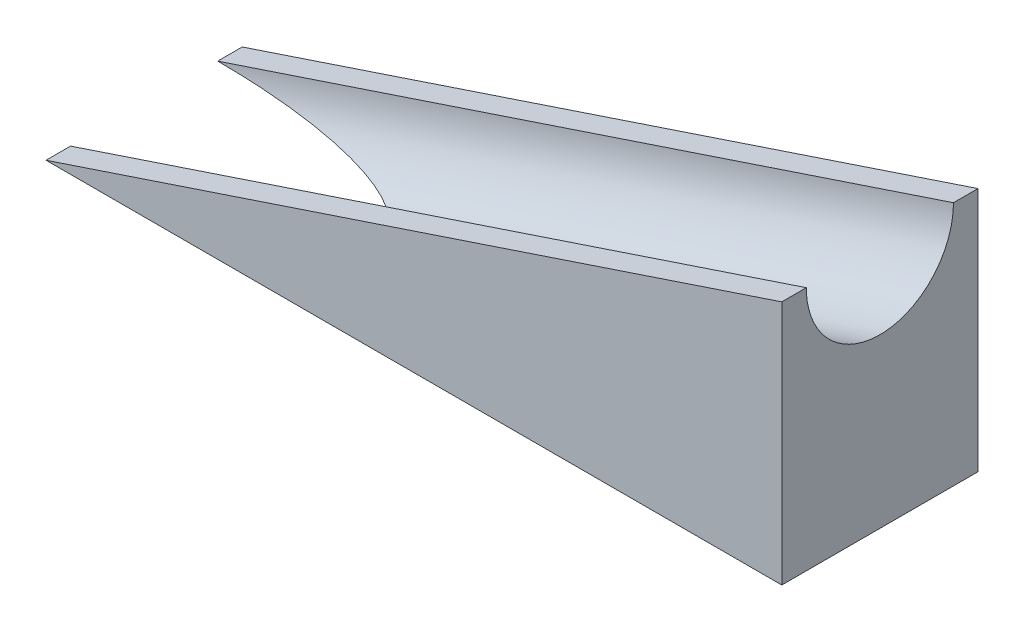
from build123d import *

# Parameters (mm, degrees)
BOSS_EXTRUDE1_DEPTH = 40
SKETCH4_R           = 15


with BuildPart() as part:
    # Sketch1 → Boss-Extrude1 (new body)
    with BuildSketch(Plane.XY):
        Polygon((150, 50), (0, 0), (150, 0), align=None)
    extrude(amount=BOSS_EXTRUDE1_DEPTH)

    # Cut-Sweep1: sweep along a curve in space
    with BuildLine() as cut_sweep1_path:
        Line((150, 50, 20), (0, 0, 20))
    # Sketch4 → Cut-Sweep1 (sweep, cut)
    with BuildSketch(Plane(origin=(150, 50, 0), x_dir=(0, 0, 1), z_dir=(-0.948683298, -0.316227766, 0))):
        with Locations((20, 0)):
            Circle(SKETCH4_R)
    sweep(path=cut_sweep1_path.line, mode=Mode.SUBTRACT)


solid = part.part
